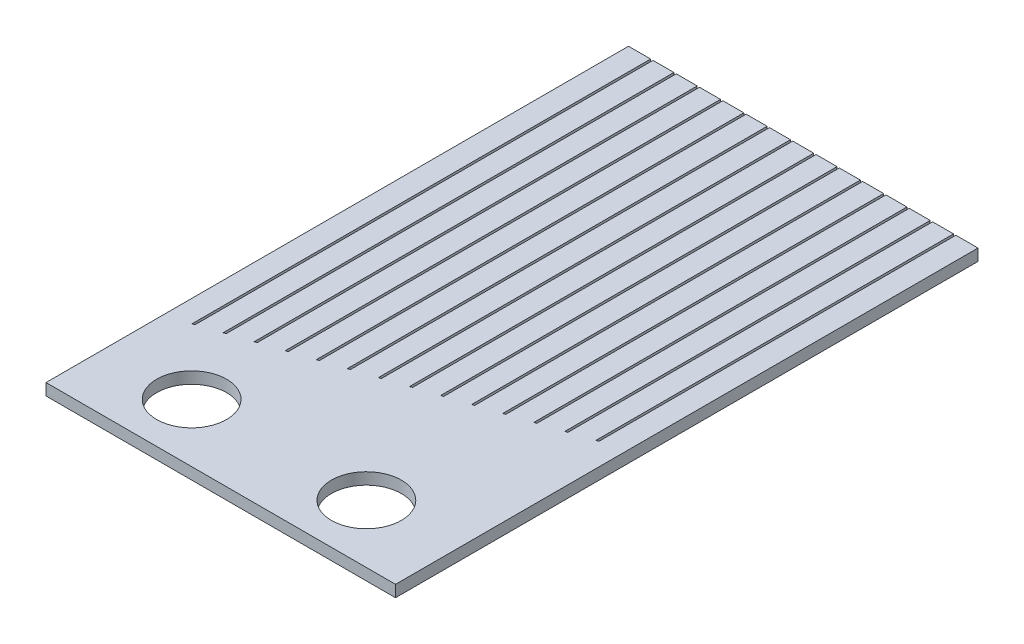
from build123d import *

# Parameters (mm, degrees)
SKETCH1_R           = 1.5
BOSS_EXTRUDE1_DEPTH = 0.5


with BuildPart() as part:
    # Sketch1 → Boss-Extrude1 (new body)
    with BuildSketch(Plane(origin=(0, 0, 0), x_dir=(1, 0, 0), z_dir=(0, 1, 0))):
        Polygon((-6.55, -7.183333333), (-7.5, -7.5), (-7.5, -12.5), (7.5, -12.5), (7.5, -2.5), (6.55, -2.816666667), (6.45, -2.85), (5.55, -3.15), (5.45, -3.183333333), (4.55, -3.483333333), (4.45, -3.516666667), (3.55, -3.816666667), (3.45, -3.85), (2.55, -4.15), (2.45, -4.183333333), (1.55, -4.483333333), (1.45, -4.516666667), (0.55, -4.816666667), (0.45, -4.85), (-0.45, -5.15), (-0.55, -5.183333333), (-1.45, -5.483333333), (-1.55, -5.516666667), (-2.45, -5.816666667), (-2.55, -5.85), (-3.45, -6.15), (-3.55, -6.183333333), (-4.45, -6.483333333), (-4.55, -6.516666667), (-5.45, -6.816666667), (-5.55, -6.85), (-6.45, -7.15), align=None)
        with Locations((-3.75, -10)):
            Circle(SKETCH1_R, mode=Mode.SUBTRACT)
        with Locations((3.75, -10)):
            Circle(SKETCH1_R, mode=Mode.SUBTRACT)
        Polygon((6.55, -2.816666667), (7.5, -2.5), (7.5, 12.5), (6.55, 12.5), align=None)
        Polygon((5.55, -3.15), (6.45, -2.85), (6.45, 12.5), (5.55, 12.5), align=None)
        Polygon((4.55, -3.483333333), (5.45, -3.183333333), (5.45, 12.5), (4.55, 12.5), align=None)
        Polygon((3.55, -3.816666667), (4.45, -3.516666667), (4.45, 12.5), (3.55, 12.5), align=None)
        Polygon((2.55, -4.15), (3.45, -3.85), (3.45, 12.5), (2.55, 12.5), align=None)
        Polygon((1.55, -4.483333333), (2.45, -4.183333333), (2.45, 12.5), (1.55, 12.5), align=None)
        Polygon((0.55, -4.816666667), (1.45, -4.516666667), (1.45, 12.5), (0.55, 12.5), align=None)
        Polygon((-0.45, 12.5), (-0.45, -5.15), (0.45, -4.85), (0.45, 12.5), align=None)
        Polygon((-1.45, 12.5), (-1.45, -5.483333333), (-0.55, -5.183333333), (-0.55, 12.5), align=None)
        Polygon((-2.45, 12.5), (-2.45, -5.816666667), (-1.55, -5.516666667), (-1.55, 12.5), align=None)
        Polygon((-3.45, 12.5), (-3.45, -6.15), (-2.55, -5.85), (-2.55, 12.5), align=None)
        Polygon((-4.45, 12.5), (-4.45, -6.483333333), (-3.55, -6.183333333), (-3.55, 12.5), align=None)
        Polygon((-5.45, 12.5), (-5.45, -6.816666667), (-4.55, -6.516666667), (-4.55, 12.5), align=None)
        Polygon((-6.45, 12.5), (-6.45, -7.15), (-5.55, -6.85), (-5.55, 12.5), align=None)
        Polygon((-7.5, 12.5), (-7.5, -7.5), (-6.55, -7.183333333), (-6.55, 12.5), align=None)
    extrude(amount=BOSS_EXTRUDE1_DEPTH)


solid = part.part
